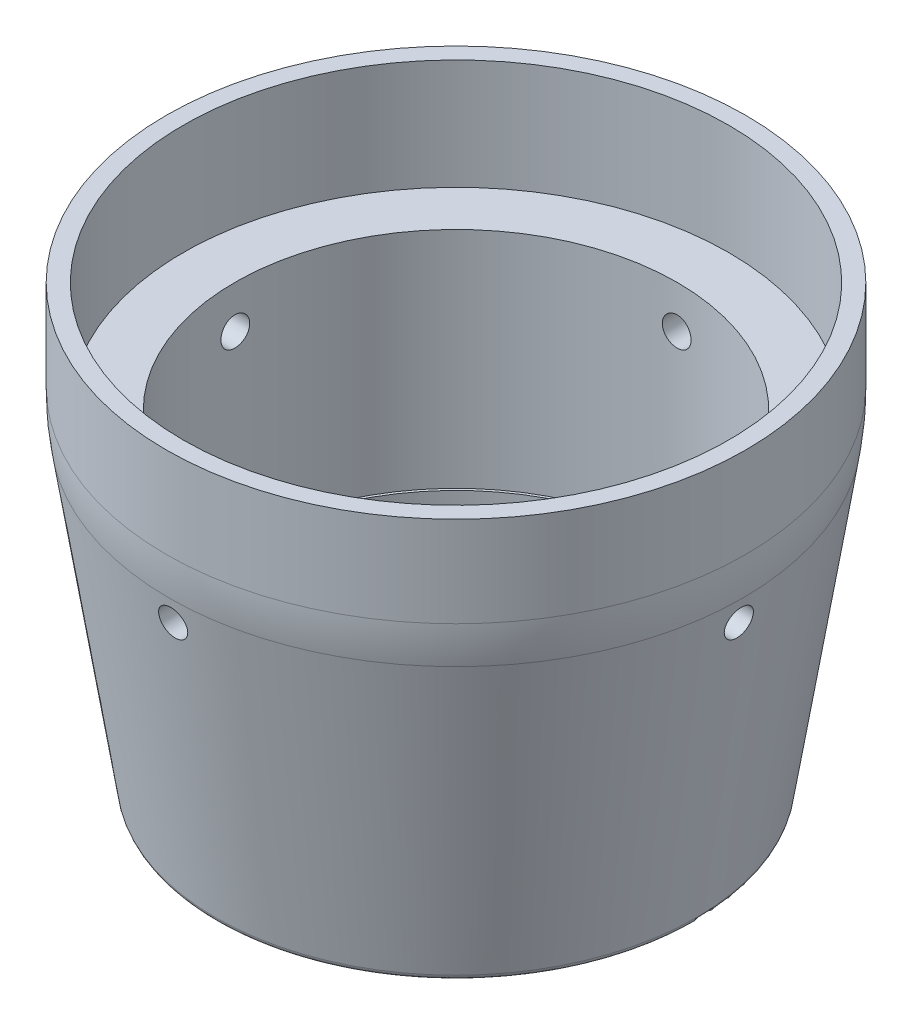
from build123d import *

# Parameters (mm, degrees)
F_6_40_TAPPED_HOLE1_REACH  = 74.325
F_6_40_TAPPED_HOLE1_BORE_R = 1.4351
CIRPATTERN1_COUNT          = 4
FILLET1_R                  = 0.635
FILLET2_R                  = 25.4


with BuildPart() as part:
    # Sketch2 → Revolve1 (revolve)
    with BuildSketch(Plane.XY, mode=Mode.PRIVATE) as revolve1_sk:
        Polygon((22.0472, -22.4282), (22.0472, -0.0762), (27.1907, -0.0762), (27.1907, 10.922), (28.8925, 10.922), (28.8925, -0.0762), (23.8252, -32.512), (21.7932, -32.512), (21.7932, -22.4282), align=None)
    revolve(revolve1_sk.sketch.rotate(Axis((0, -34.5451, 0), (0, 1, 0)), 90), axis=Axis((0, -34.5451, 0), (0, 1, 0)))

    # #6-40 Tapped Hole1 bore → #6-40 Tapped Hole1 (cut, up to next)
    with BuildSketch(Plane.XY.offset(28.8925), mode=Mode.PRIVATE) as f_6_40_tapped_hole1_sk1:
        with Locations((0, -4.318)):
            Circle(F_6_40_TAPPED_HOLE1_BORE_R)
    f_6_40_tapped_hole1_tool1 = extrude(f_6_40_tapped_hole1_sk1.sketch, amount=-F_6_40_TAPPED_HOLE1_REACH, mode=Mode.PRIVATE) & part.part
    f_6_40_tapped_hole1 = f_6_40_tapped_hole1_tool1.solids().sort_by_distance((0, -4.318, 28.8925))[0]
    add(f_6_40_tapped_hole1, mode=Mode.SUBTRACT)

    # CirPattern1: #6-40 Tapped Hole1 ×4 about axis
    cirpattern1_axis = Axis((0, -34.5451, 0), (0, -1, 0))
    for i in range(1, CIRPATTERN1_COUNT):
        add(f_6_40_tapped_hole1.rotate(cirpattern1_axis, i * 360 / CIRPATTERN1_COUNT), mode=Mode.SUBTRACT)

    # Fillet1
    fillet1_edges = [part.edges().sort_by_distance(p)[0] for p in [
        (0, -32.512, 23.8252),
    ]]
    fillet(fillet1_edges, radius=FILLET1_R)

    # Fillet2
    fillet2_edges = [part.edges().sort_by_distance(p)[0] for p in [
        (0, -0.0762, 28.8925),
    ]]
    fillet(fillet2_edges, radius=FILLET2_R)


solid = part.part
